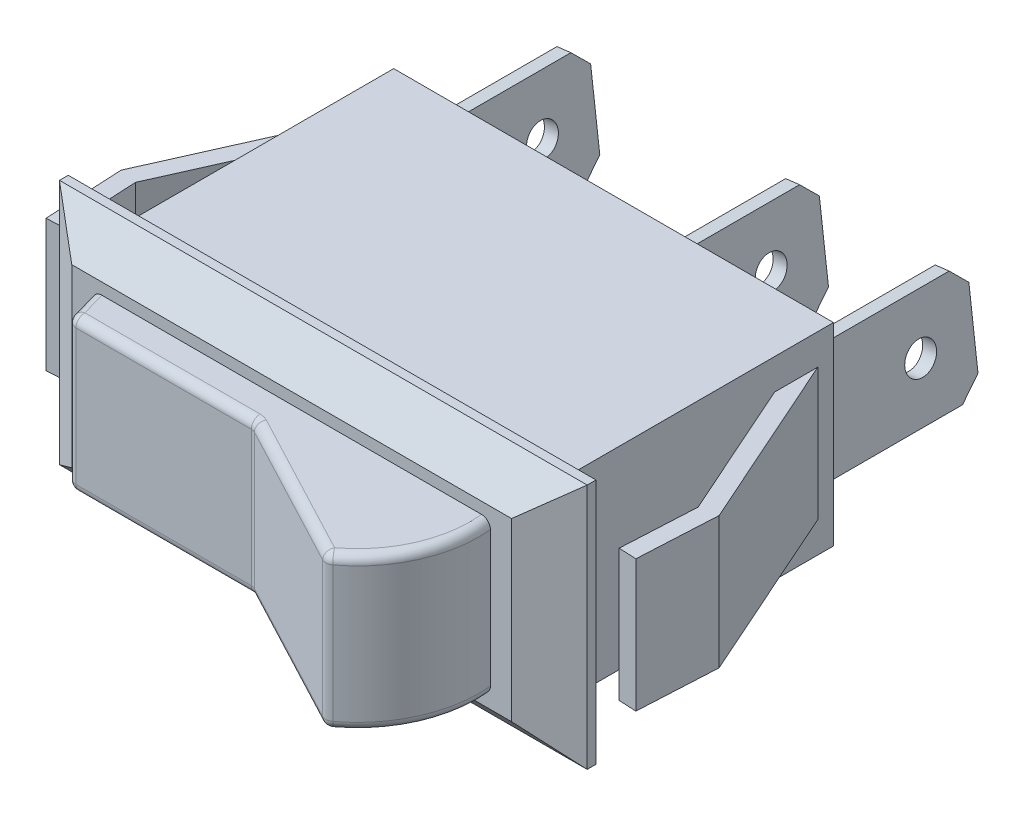
from build123d import *

# Parameters (mm, degrees)
SKETCH1_W             = 25
SKETCH1_H             = 11
EXTRUDE1_DEPTH        = 16
SKETCH2_W             = 30
SKETCH2_H             = 14
EXTRUDE2_DEPTH        = 2.3
CHAMFER1_SIZE         = 1.8
CHAMFER1_SIZE2        = 2
CHAMFER1_PART_2_SIZE  = 1.8
CHAMFER1_PART_2_SIZE2 = 2
CHAMFER2_SIZE         = 1.8
CHAMFER2_SIZE2        = 2.5
CHAMFER2_PART_2_SIZE  = 1.8
CHAMFER2_PART_2_SIZE2 = 2.5
EXTRUDE3_DEPTH        = 3.75
EXTRUDE4_DEPTH        = 4.35
EXTRUDE4_DEPTH_BACK   = 4.35
FILLET1_R             = 0.5
SKETCH7_W             = 25
SKETCH7_H             = 2.5
CUT_EXTRUDE2_DEPTH    = 0.44
SKETCH8_R             = 0.9
EXTRUDE5_DEPTH        = 0.8
LPATTERN1_COUNT       = 2
LPATTERN1_PITCH       = 13
LPATTERN2_COUNT       = 2
LPATTERN2_PITCH       = 21.5


with BuildPart() as part:
    # Sketch1 → Extrude1 (new body)
    with BuildSketch(Plane.XY):
        with Locations((12.5, 5.5)):
            Rectangle(SKETCH1_W, SKETCH1_H)
    extrude(amount=EXTRUDE1_DEPTH)

    # Sketch2 → Extrude2 (add)
    with BuildSketch(Plane.XY.offset(16)):
        with Locations((12.5, 5.5)):
            Rectangle(SKETCH2_W, SKETCH2_H)
    extrude(amount=EXTRUDE2_DEPTH)

    # Chamfer1
    chamfer1_edges = [part.edges().sort_by_distance(p)[0] for p in [
        (12.5, -1.5, 18.3),
    ]]
    chamfer1_side = [part.faces().sort_by_distance(p)[0] for p in [
        (12.5, -1.5, 17.15),
    ]]
    chamfer(chamfer1_edges, length=CHAMFER1_SIZE, length2=CHAMFER1_SIZE2, reference=chamfer1_side[0])

    # Chamfer1 part 2
    chamfer1_part_2_edges = [part.edges().sort_by_distance(p)[0] for p in [
        (12.5, 12.5, 18.3),
    ]]
    chamfer1_part_2_side = [part.faces().sort_by_distance(p)[0] for p in [
        (12.5, 12.5, 17.15),
    ]]
    chamfer(chamfer1_part_2_edges, length=CHAMFER1_PART_2_SIZE, length2=CHAMFER1_PART_2_SIZE2, reference=chamfer1_part_2_side[0])

    # Chamfer2
    chamfer2_edges = [part.edges().sort_by_distance(p)[0] for p in [
        (27.5, 5.5, 18.3),
    ]]
    chamfer2_side = [part.faces().sort_by_distance(p)[0] for p in [
        (27.5, 5.5, 17.080769231),
    ]]
    chamfer(chamfer2_edges, length=CHAMFER2_SIZE, length2=CHAMFER2_SIZE2, reference=chamfer2_side[0])

    # Chamfer2 part 2
    chamfer2_part_2_edges = [part.edges().sort_by_distance(p)[0] for p in [
        (-2.5, 5.5, 18.3),
    ]]
    chamfer2_part_2_side = [part.faces().sort_by_distance(p)[0] for p in [
        (-2.5, 5.5, 17.080769231),
    ]]
    chamfer(chamfer2_part_2_edges, length=CHAMFER2_PART_2_SIZE, length2=CHAMFER2_PART_2_SIZE2, reference=chamfer2_part_2_side[0])

    # Sketch4 → Extrude3 (add, symmetric)
    with BuildSketch(Plane(origin=(0, 5.5, 0), x_dir=(-1, 0, 0), z_dir=(0, 1, 0))):
        Polygon((0, 0.892834517), (4.5, 11), (4.264164993, 15.5), (3.265535458, 15.447664044), (3.488805714, 11.187413783), (0, 3.351427853), align=None)
    extrude3 = extrude(amount=EXTRUDE3_DEPTH, both=True)

    # Mirror1: Extrude3 across plane
    add(extrude3.mirror(Plane(origin=(12.5, 0, 0), x_dir=(0, 0, 1), z_dir=(1, 0, 0))))

    # Sketch6 → Extrude4 (add, two sides)
    with BuildSketch(Plane(origin=(0, 5.5, 0), x_dir=(-1, 0, 0), z_dir=(0, 1, 0))) as extrude4_sk:
        with BuildLine():
            Line((-1.2, 18.3), (-1.710738672, 20.15))
            Line((-1.710738672, 20.15), (-12.18088144, 20.15))
            Line((-12.18088144, 20.15), (-20.793792675, 24.7))
            ThreePointArc((-20.793792675, 24.7), (-23.177832074, 21.913793041), (-23.8, 18.3))
            Line((-23.8, 18.3), (-1.2, 18.3))
        make_face()
    extrude(amount=EXTRUDE4_DEPTH)
    extrude(extrude4_sk.sketch, amount=-EXTRUDE4_DEPTH_BACK)

    # Fillet1
    fillet1_edges = [part.edges().sort_by_distance(p)[0] for p in [
        (1.455369336, 1.15, 19.225),
        (1.710738672, 5.5, 20.15),
        (6.945810056, 1.15, 20.15),
        (12.18088144, 5.5, 20.15),
        (16.487337058, 1.15, 22.425),
        (20.793792675, 5.5, 24.7),
        (23.177832074, 1.15, 21.913793041),
        (1.455369336, 9.85, 19.225),
        (6.945810056, 9.85, 20.15),
        (16.487337058, 9.85, 22.425),
        (23.177832074, 9.85, 21.913793041),
    ]]
    fillet(fillet1_edges, radius=FILLET1_R)

    # Sketch7 → Cut-Extrude2 (cut)
    with BuildSketch(Plane.XZ):
        with Locations((12.5, 6.25)):
            Rectangle(SKETCH7_W, SKETCH7_H)
    extrude(amount=-CUT_EXTRUDE2_DEPTH, mode=Mode.SUBTRACT)

    # Sketch8 → Extrude5 (add)
    with BuildSketch(Plane(origin=(1.985092303, 0.243738687, 0), x_dir=(0, 0, -1), z_dir=(0.992546152, 0.121869343, 0))):
        Polygon((8.3, 1.992800038), (9.3, 2.992800038), (9.3, 7.242800038), (8.3, 8.242800038), (0.5, 8.242800038), (0, 7.742800038), (0, 2.492800038), (0.5, 1.992800038), align=None)
        with Locations((6.3, 5.117800038)):
            Circle(SKETCH8_R, mode=Mode.SUBTRACT)
    extrude5 = extrude(amount=EXTRUDE5_DEPTH)

    # LPattern1: Extrude5 ×2
    with Locations(*[(i * LPATTERN1_PITCH, 0, 0) for i in range(1, LPATTERN1_COUNT)]):
        add(extrude5)

    # LPattern2: Extrude5 ×2
    with Locations(*[(i * LPATTERN2_PITCH, 0, 0) for i in range(1, LPATTERN2_COUNT)]):
        add(extrude5)


solid = part.part
